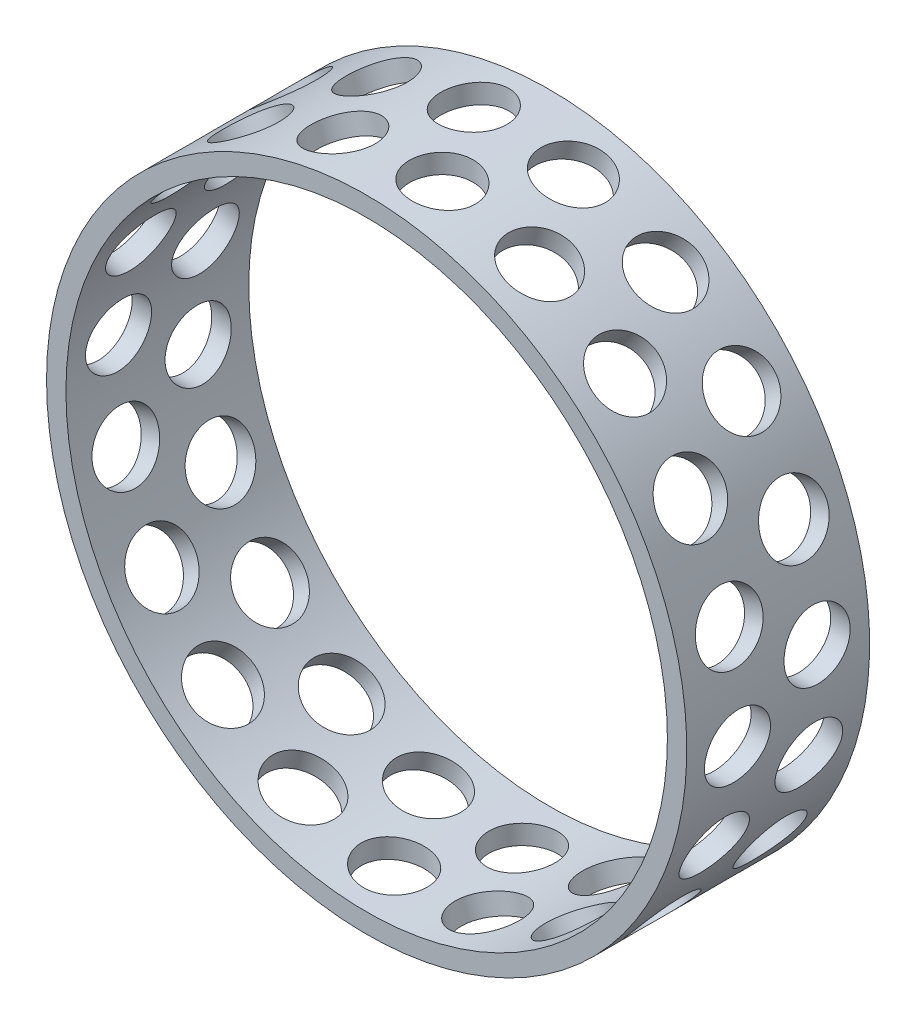
from build123d import *

# Parameters (mm, degrees)
SKETCH1_W          = 47.15
SKETCH1_H          = 5
SKETCH2_R          = 8.5
CUT_EXTRUDE1_DEPTH = 83.55
CIRPATTERN1_COUNT  = 20


with BuildPart() as part:
    # Sketch1 → Revolve1 (revolve)
    with BuildSketch(Plane(origin=(0, 0, 0), x_dir=(0, 0, -1), z_dir=(1, 0, 0))):
        with Locations((24.575, 80.05)):
            Rectangle(SKETCH1_W, SKETCH1_H)
    revolve(axis=Axis((0, 0, -50.5075), (0, 0, 1)))

    # Sketch2 → Cut-Extrude1 (cut, through all)
    with BuildSketch(Plane(origin=(0, 0, 0), x_dir=(0, 0, -1), z_dir=(1, 0, 0))):
        with Locations((14.309765987, 6.214899086)):
            Circle(SKETCH2_R)
        with Locations((34.840234013, -6.214899086)):
            Circle(SKETCH2_R)
    cut_extrude1 = extrude(amount=-CUT_EXTRUDE1_DEPTH, mode=Mode.SUBTRACT)

    # CirPattern1: Cut-Extrude1 ×20 about axis
    cirpattern1_axis = Axis((0, 0, -50.5075), (0, 0, 1))
    for i in range(1, CIRPATTERN1_COUNT):
        add(cut_extrude1.rotate(cirpattern1_axis, i * 360 / CIRPATTERN1_COUNT), mode=Mode.SUBTRACT)


solid = part.part
